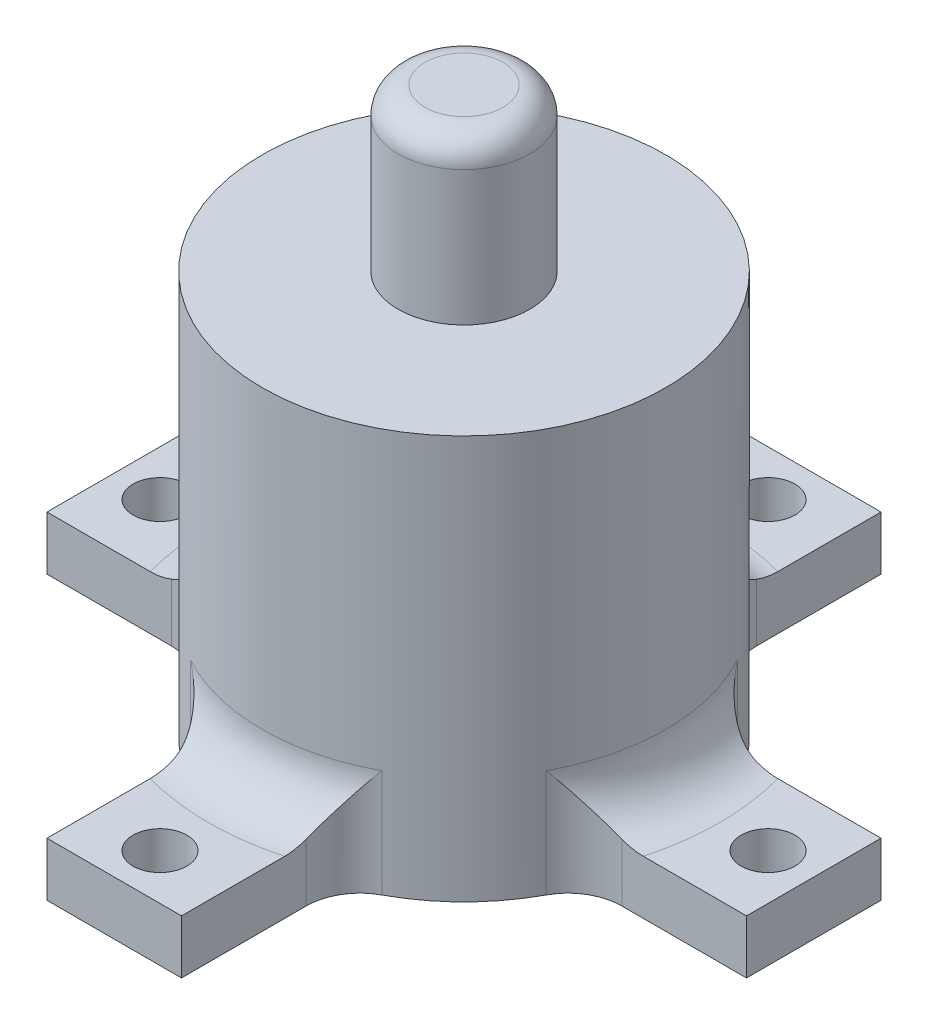
from build123d import *

# Parameters (mm, degrees)
SKETCH1_R             = 7.5
BOSS_EXTRUDE1_DEPTH   = 15
SKETCH2_R             = 2.45
BOSS_EXTRUDE2_DEPTH   = 6
SKETCH3_W             = 10.5
SKETCH3_H             = 5
SKETCH3_W_2           = 5
SKETCH3_H_2           = 10.5
BOSS_EXTRUDE3_DEPTH   = 2
FILLET1_R             = 2
F_2_0MM_DOWEL_HOLE1_D = 2
FILLET2_R             = 1


with BuildPart() as part:
    # Sketch1 → Boss-Extrude1 (new body)
    with BuildSketch(Plane(origin=(0, 0, 0), x_dir=(1, 0, 0), z_dir=(0, 1, 0))):
        Circle(SKETCH1_R)
    extrude(amount=BOSS_EXTRUDE1_DEPTH)

    # Sketch2 → Boss-Extrude2 (add)
    with BuildSketch(Plane(origin=(0, 15, 0), x_dir=(1, 0, 0), z_dir=(0, 1, 0))):
        Circle(SKETCH2_R)
    extrude(amount=BOSS_EXTRUDE2_DEPTH)

    # Sketch3 → Boss-Extrude3 (add)
    with BuildSketch(Plane(origin=(0, 0, 0), x_dir=(1, 0, 0), z_dir=(0, 1, 0))):
        with Locations((-7.75, 0)):
            Rectangle(SKETCH3_W, SKETCH3_H)
        with Locations((0, -7.75)):
            Rectangle(SKETCH3_W_2, SKETCH3_H_2)
        with Locations((7.75, 0)):
            Rectangle(SKETCH3_W, SKETCH3_H)
        with Locations((0, 7.75)):
            Rectangle(SKETCH3_W_2, SKETCH3_H_2)
    extrude(amount=BOSS_EXTRUDE3_DEPTH)

    # Fillet1
    fillet1_edges = [part.edges().sort_by_distance(p)[0] for p in [
        (-7.5, 2, 0),
        (-7.071067812, 1, 2.5),
        (-7.071067812, 1, -2.5),
        (0, 2, 7.5),
        (-2.5, 1, 7.071067812),
        (2.5, 1, 7.071067812),
        (7.391989197, 2, -1.26826484),
        (7.071067812, 1, 2.5),
        (7.071067812, 1, -2.5),
        (0, 2, -7.5),
        (-2.5, 1, -7.071067812),
        (2.5, 1, -7.071067812),
    ]]
    fillet(fillet1_edges, radius=FILLET1_R)

    # Ø2.0mm Dowel Hole1 (through all)
    with Locations(Plane(origin=(-11.3, 2, 0), x_dir=(0, 0, 1), z_dir=(0, 1, 0))):
        with Locations((0, 0), (-11.3, 11.3), (0, 22.6), (11.3, 11.3)):
            Hole(F_2_0MM_DOWEL_HOLE1_D / 2)

    # Fillet2
    fillet2_edges = [part.edges().sort_by_distance(p)[0] for p in [
        (-2.45, 21, 0),
    ]]
    fillet(fillet2_edges, radius=FILLET2_R)


solid = part.part
